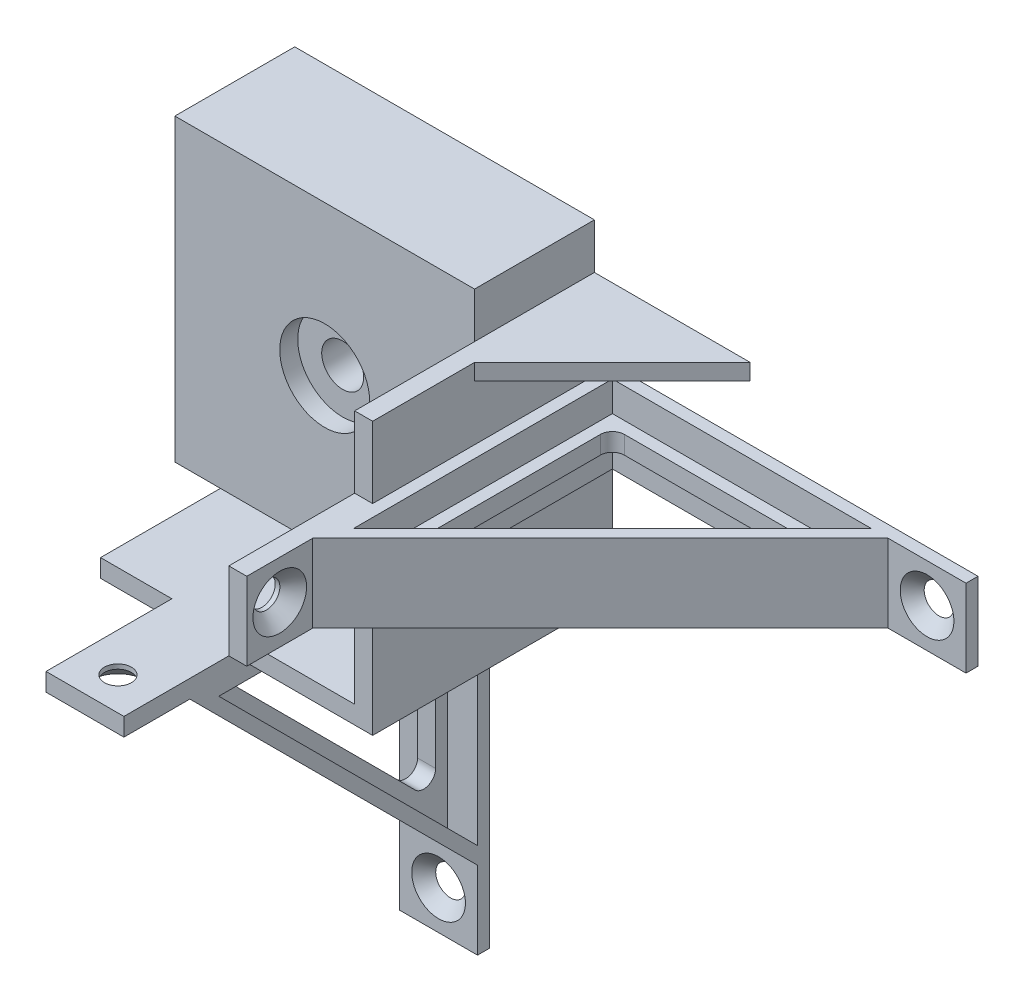
from build123d import *

# Parameters (mm, degrees)
CROQUIS2_W                                           = 50
CROQUIS2_H                                           = 50
CROQUIS2_R                                           = 3.5
SALIENTE_EXTRUIR2_DEPTH                              = 20
CROQUIS3_R                                           = 7.5
CORTAR_EXTRUIR1_DEPTH                                = 3
SALIENTE_EXTRUIR3_DEPTH                              = 40
SALIENTE_EXTRUIR4_DEPTH                              = 2.65
CORTAR_EXTRUIR2_START                                = -2
CORTAR_EXTRUIR2_DEPTH                                = 5
SALIENTE_EXTRUIR5_START                              = -20.5
SALIENTE_EXTRUIR5_DEPTH                              = 13
SALIENTE_EXTRUIR6_START                              = -5
SALIENTE_EXTRUIR6_DEPTH                              = 3
REDONDEO1_R                                          = 2
CROQUIS12_R                                          = 2
CORTAR_EXTRUIR4_DEPTH                                = 2
CROQUIS13_R                                          = 2
CORTAR_EXTRUIR5_DEPTH                                = 3
REFRENTADO_PARA_TORNILLO_TAP_N_CON_CABEZ_D           = 4.5
REFRENTADO_PARA_TORNILLO_TAP_N_CON_CABEZ_CSINK_D     = 8.96
REFRENTADO_PARA_TORNILLO_TAP_N_CON_CABEZ_CSINK_ANGLE = 90
REDONDEO1_OF_SIMETR_A4_R                             = 2


with BuildPart() as part:
    # Croquis2 → Saliente-Extruir2 (new body)
    with BuildSketch(Plane.XY):
        Rectangle(CROQUIS2_W, CROQUIS2_H)
        Circle(CROQUIS2_R, mode=Mode.SUBTRACT)
    extrude(amount=SALIENTE_EXTRUIR2_DEPTH)

    # Croquis3 → Cortar-Extruir1 (cut)
    with BuildSketch(Plane.XY.offset(20)):
        Circle(CROQUIS3_R)
    extrude(amount=-CORTAR_EXTRUIR1_DEPTH, mode=Mode.SUBTRACT)

    # Croquis4 → Saliente-Extruir3 (add)
    with BuildSketch(Plane(origin=(0, 0, 0), x_dir=(-1, 0, 0), z_dir=(0, 0, -1))):
        Polygon((-25, -25), (-25, 17.4), (-28, 17.4), (-28, -28), (17.4, -28), (17.4, -25), align=None)
    extrude(amount=-SALIENTE_EXTRUIR3_DEPTH)

    # Croquis5 → Saliente-Extruir4 (add)
    with BuildSketch(Plane(origin=(0, 17.4, 0), x_dir=(1, 0, 0), z_dir=(0, 1, 0))):
        Polygon((25, 0), (51, 0), (26, -25), (25, -25), align=None)
    saliente_extruir4 = extrude(amount=-SALIENTE_EXTRUIR4_DEPTH)

    # Croquis6 → Cortar-Extruir2 (cut)
    with BuildSketch(Plane.XZ.offset(-14.75).offset(CORTAR_EXTRUIR2_START)):
        Polygon((44.915346148, 4.67044029), (30.667144507, 18.918641931), (26.318437803, 14.569935226), (40.566639444, 0.321733585), align=None)
    cortar_extruir2 = extrude(amount=CORTAR_EXTRUIR2_DEPTH, mode=Mode.SUBTRACT)

    # Simetría2: Saliente-Extruir4, Cortar-Extruir2 across plane
    add(saliente_extruir4.mirror(Plane(origin=(0, 0, 0), x_dir=(0, 0, 1), z_dir=(0.707106781, 0.707106781, 0))))
    add(cortar_extruir2.mirror(Plane(origin=(0, 0, 0), x_dir=(0, 0, 1), z_dir=(0.707106781, 0.707106781, 0))), mode=Mode.SUBTRACT)

    # Croquis10 → Saliente-Extruir5 (add)
    with BuildSketch(Plane.XZ.offset(28).offset(SALIENTE_EXTRUIR5_START)):
        Polygon((28, 0), (78, 0), (89, 0), (89, 2), (76, 2), (28, 50), (28, 61), (25, 61), (25, 40), (28, 40), align=None)
        Polygon((30, 45.171572875), (73.171572875, 2), (30, 2), align=None, mode=Mode.SUBTRACT)
    saliente_extruir5 = extrude(amount=-SALIENTE_EXTRUIR5_DEPTH)

    # Croquis11 → Saliente-Extruir6 (add)
    with BuildSketch(Plane.XZ.offset(7.5).offset(SALIENTE_EXTRUIR6_START)):
        Polygon((30, 45.171572875), (30, 2), (73.171572875, 2), align=None)
        Polygon((32, 40.343145751), (32, 4), (68.343145751, 4), align=None, mode=Mode.SUBTRACT)
    saliente_extruir6 = extrude(amount=-SALIENTE_EXTRUIR6_DEPTH)

    # Redondeo1
    redondeo1_edges = [part.edges().sort_by_distance(p)[0] for p in [
        (68.343145751, -1, 4),
        (32, -1, 4),
        (32, -1, 40.343145751),
    ]]
    fillet(redondeo1_edges, radius=REDONDEO1_R)

    # Croquis12 → Cortar-Extruir4 (cut)
    with BuildSketch(Plane.XY.offset(2)):
        with Locations((82.5, -1)):
            Circle(CROQUIS12_R)
    cortar_extruir4 = extrude(amount=-CORTAR_EXTRUIR4_DEPTH, mode=Mode.SUBTRACT)

    # Croquis13 → Cortar-Extruir5 (cut)
    with BuildSketch(Plane(origin=(28, 0, 0), x_dir=(0, 0, -1), z_dir=(1, 0, 0))):
        with Locations((-55.5, -1)):
            Circle(CROQUIS13_R)
    cortar_extruir5 = extrude(amount=-CORTAR_EXTRUIR5_DEPTH, mode=Mode.SUBTRACT)

    # Refrentado para tornillo tap_n con cabez (through all)
    with Locations(Plane(origin=(28, 0, 0), x_dir=(0, 0, -1), z_dir=(1, 0, 0))):
        with Locations((-55.5, -1)):
            refrentado_para_tornillo_tap_n_con_cabez = CounterSinkHole(REFRENTADO_PARA_TORNILLO_TAP_N_CON_CABEZ_D / 2, REFRENTADO_PARA_TORNILLO_TAP_N_CON_CABEZ_CSINK_D / 2, counter_sink_angle=REFRENTADO_PARA_TORNILLO_TAP_N_CON_CABEZ_CSINK_ANGLE)

    # Croquis17 → Refrentado para tornillo tap_n con c 2 (revolve, cut)
    with BuildSketch(Plane(origin=(82.5, -1, 2), x_dir=(0, -1, 0), z_dir=(1, 0, 0))):
        Polygon((0, 0), (0, 2), (2.25, 2), (2.25, 2.23), (4.48, 0), align=None)
    refrentado_para_tornillo_tap_n_con_c_2 = revolve(axis=Axis((82.5, -1, 8.35), (0, 0, -1)), mode=Mode.SUBTRACT)

    # Simetría4: Saliente-Extruir5, Saliente-Extruir6, Cortar-Extruir4, Cortar-Extruir5, Refrentado para tornillo tap_n con cabez, Refrentado para tornillo tap_n con c 2 across plane
    add(saliente_extruir5.mirror(Plane(origin=(0, 0, 0), x_dir=(0, 0, 1), z_dir=(0.707106781, 0.707106781, 0))))
    add(saliente_extruir6.mirror(Plane(origin=(0, 0, 0), x_dir=(0, 0, 1), z_dir=(0.707106781, 0.707106781, 0))))
    add(cortar_extruir4.mirror(Plane(origin=(0, 0, 0), x_dir=(0, 0, 1), z_dir=(0.707106781, 0.707106781, 0))), mode=Mode.SUBTRACT)
    add(cortar_extruir5.mirror(Plane(origin=(0, 0, 0), x_dir=(0, 0, 1), z_dir=(0.707106781, 0.707106781, 0))), mode=Mode.SUBTRACT)
    add(refrentado_para_tornillo_tap_n_con_cabez.mirror(Plane(origin=(0, 0, 0), x_dir=(0, 0, 1), z_dir=(0.707106781, 0.707106781, 0))), mode=Mode.SUBTRACT)
    add(refrentado_para_tornillo_tap_n_con_c_2.mirror(Plane(origin=(0, 0, 0), x_dir=(0, 0, 1), z_dir=(0.707106781, 0.707106781, 0))), mode=Mode.SUBTRACT)

    # Redondeo1 of Simetría4
    redondeo1_of_simetr_a4_edges = [part.edges().sort_by_distance(p)[0] for p in [
        (1, -68.343145751, 4),
        (1, -32, 4),
        (1, -32, 40.343145751),
    ]]
    fillet(redondeo1_of_simetr_a4_edges, radius=REDONDEO1_OF_SIMETR_A4_R)


solid = part.part
